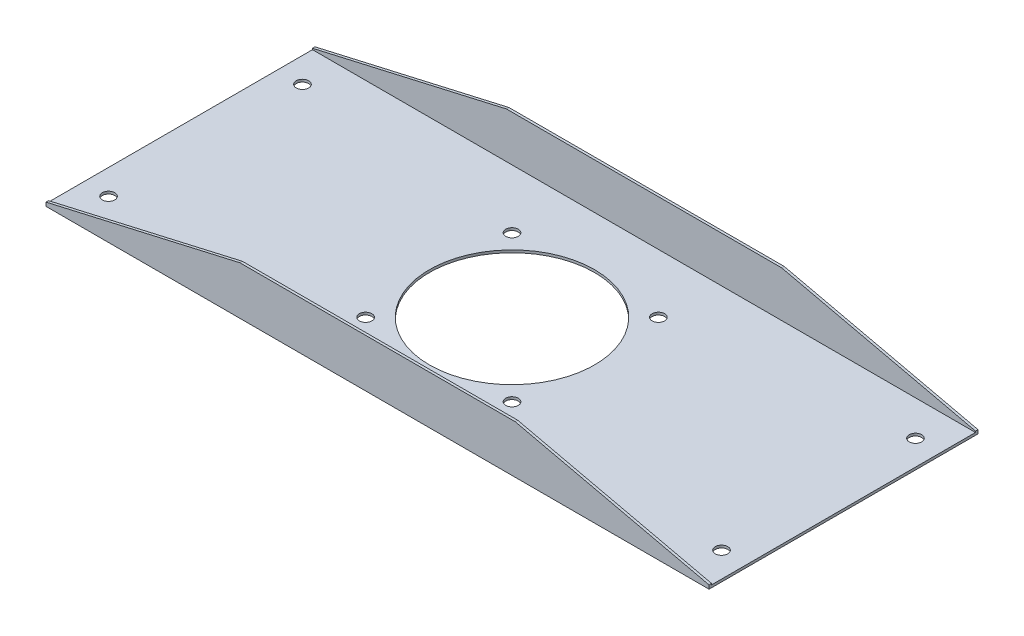
from build123d import *

# Parameters (mm, degrees)
EXTRUDE_1_DEPTH     = 530
SKETCH_2_OUTSIDE_W  = 646.648
SKETCH_2_OUTSIDE_H  = 155.148
CUT_EXTRUDE_2_DEPTH = 216
SKETCH_3_R          = 5
SKETCH_3_R_2        = 66
CUT_EXTRUDE_3_DEPTH = 3


with BuildPart() as part:
    # Эскиз1 → Вытянуть-Тонкостенный1 (new body)
    with BuildSketch(Plane(origin=(0, 0, 0), x_dir=(0, 0, -1), z_dir=(1, 0, 0))):
        Polygon((-105, 38.5), (-105, 0), (110, 0), (110, 38.5), (108, 38.5), (108, 2), (-103, 2), (-103, 38.5), align=None)
    extrude(amount=EXTRUDE_1_DEPTH)

    # Эскиз2 outside → Вырез-Вытянуть2 (cut, through all)
    with BuildSketch(Plane(origin=(0, 0, -110), x_dir=(-1, 0, 0), z_dir=(0, 0, -1))):
        with Locations((-265, 19.25)):
            Rectangle(SKETCH_2_OUTSIDE_W, SKETCH_2_OUTSIDE_H)
        Polygon((-530, 0), (-530, 3), (-375, 38.5), (-155, 38.5), (0, 3), (0, 0), align=None, mode=Mode.SUBTRACT)
    extrude(amount=-CUT_EXTRUDE_2_DEPTH, mode=Mode.SUBTRACT)

    # Эскиз3 → Вырез-Вытянуть3 (cut, through all)
    with BuildSketch(Plane(origin=(0, 2, 0), x_dir=(1, 0, 0), z_dir=(0, 1, 0))):
        with Locations((20, 80)):
            Circle(SKETCH_3_R)
        with Locations((20, -75)):
            Circle(SKETCH_3_R)
        with Locations((510, 80)):
            Circle(SKETCH_3_R)
        with Locations((510, -75)):
            Circle(SKETCH_3_R)
        with Locations((265, 2.5)):
            Circle(SKETCH_3_R_2)
        with Locations((323.513972874, 61.013972874)):
            Circle(SKETCH_3_R)
        with Locations((323.513972874, -56.013972874)):
            Circle(SKETCH_3_R)
        with Locations((206.486027126, -56.013972874)):
            Circle(SKETCH_3_R)
        with Locations((206.486027126, 61.013972874)):
            Circle(SKETCH_3_R)
    extrude(amount=-CUT_EXTRUDE_3_DEPTH, mode=Mode.SUBTRACT)


solid = part.part
